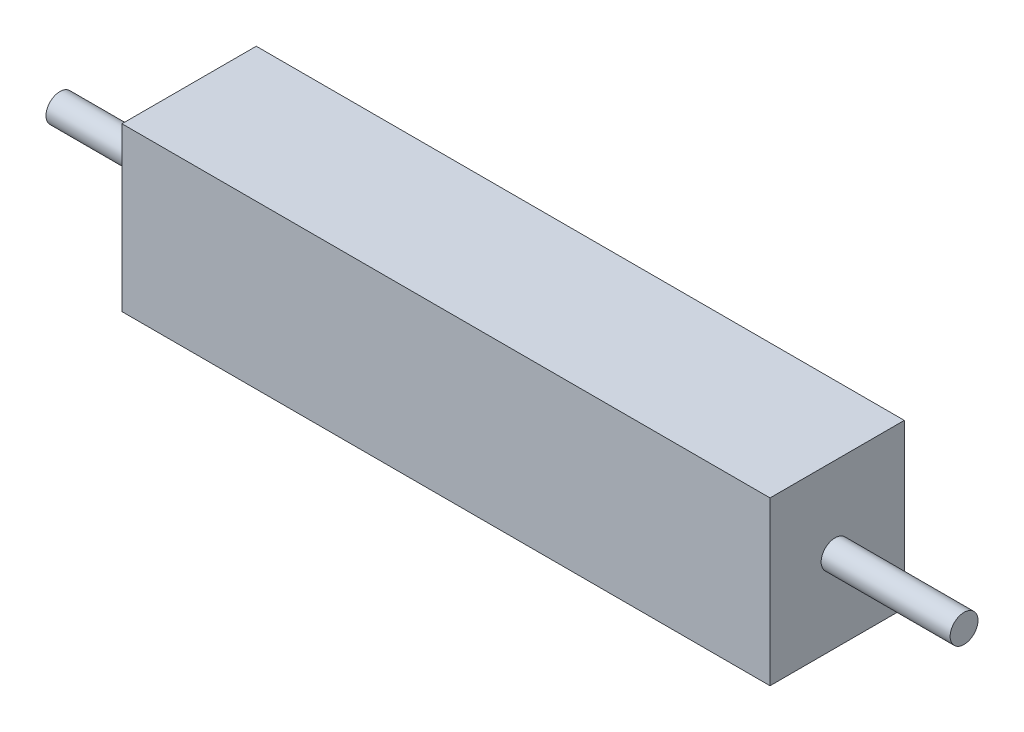
from build123d import *

# Parameters (mm, degrees)
SKETCH1_W           = 11.63
SKETCH1_H           = 2.41
BOSS_EXTRUDE1_DEPTH = 2.92
SKETCH2_R           = 0.25
BOSS_EXTRUDE2_DEPTH = 2.315
SKETCH3_R           = 0.25
BOSS_EXTRUDE3_DEPTH = 2.315


with BuildPart() as part:
    # Sketch1 → Boss-Extrude1 (new body)
    with BuildSketch(Plane(origin=(0, 0, 0), x_dir=(1, 0, 0), z_dir=(0, 1, 0))):
        with Locations((5.815, 1.205)):
            Rectangle(SKETCH1_W, SKETCH1_H)
    extrude(amount=BOSS_EXTRUDE1_DEPTH)

    # Sketch2 → Boss-Extrude2 (add)
    with BuildSketch(Plane(origin=(11.63, 0, 0), x_dir=(0, 0, -1), z_dir=(1, 0, 0))):
        with Locations((1.167158441, 1.465733238)):
            Circle(SKETCH2_R)
    extrude(amount=BOSS_EXTRUDE2_DEPTH)

    # Sketch3 → Boss-Extrude3 (add)
    with BuildSketch(Plane.ZY):
        with Locations((-1.201708257, 1.412791091)):
            Circle(SKETCH3_R)
    extrude(amount=BOSS_EXTRUDE3_DEPTH)


solid = part.part
